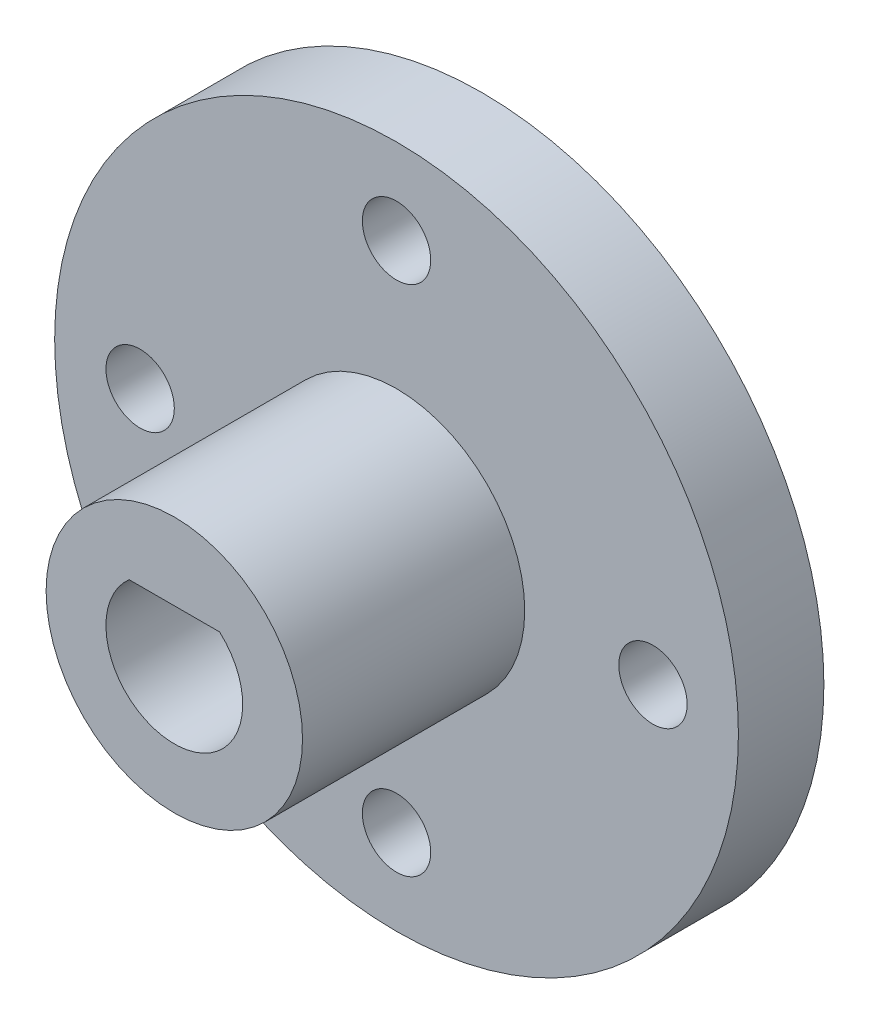
from build123d import *

# Parameters (mm, degrees)
SKETCH1_R           = 20
BOSS_EXTRUDE1_DEPTH = 5
SKETCH2_R           = 7.5
BOSS_EXTRUDE2_DEPTH = 13
CUT_EXTRUDE1_DEPTH  = 18
SKETCH4_R           = 2
CUT_EXTRUDE2_DEPTH  = 18


with BuildPart() as part:
    # Sketch1 → Boss-Extrude1 (new body)
    with BuildSketch(Plane.XY):
        Circle(SKETCH1_R)
    extrude(amount=BOSS_EXTRUDE1_DEPTH)

    # Sketch2 → Boss-Extrude2 (add)
    with BuildSketch(Plane.XY.offset(5)):
        Circle(SKETCH2_R)
    extrude(amount=BOSS_EXTRUDE2_DEPTH)

    # Sketch3 → Cut-Extrude1 (cut)
    with BuildSketch(Plane.XY.offset(18)):
        with BuildLine():
            Line((-2.645751311, 3), (2.645751311, 3))
            ThreePointArc((2.645751311, 3), (0, -4), (-2.645751311, 3))
        make_face()
    extrude(amount=-CUT_EXTRUDE1_DEPTH, mode=Mode.SUBTRACT)

    # Sketch4 → Cut-Extrude2 (cut)
    with BuildSketch(Plane.XY.offset(5)):
        with Locations((0, 15)):
            Circle(SKETCH4_R)
        with Locations((15, 0)):
            Circle(SKETCH4_R)
        with Locations((0, -15)):
            Circle(SKETCH4_R)
        with Locations((-15, 0)):
            Circle(SKETCH4_R)
    extrude(amount=-CUT_EXTRUDE2_DEPTH, mode=Mode.SUBTRACT)


solid = part.part
